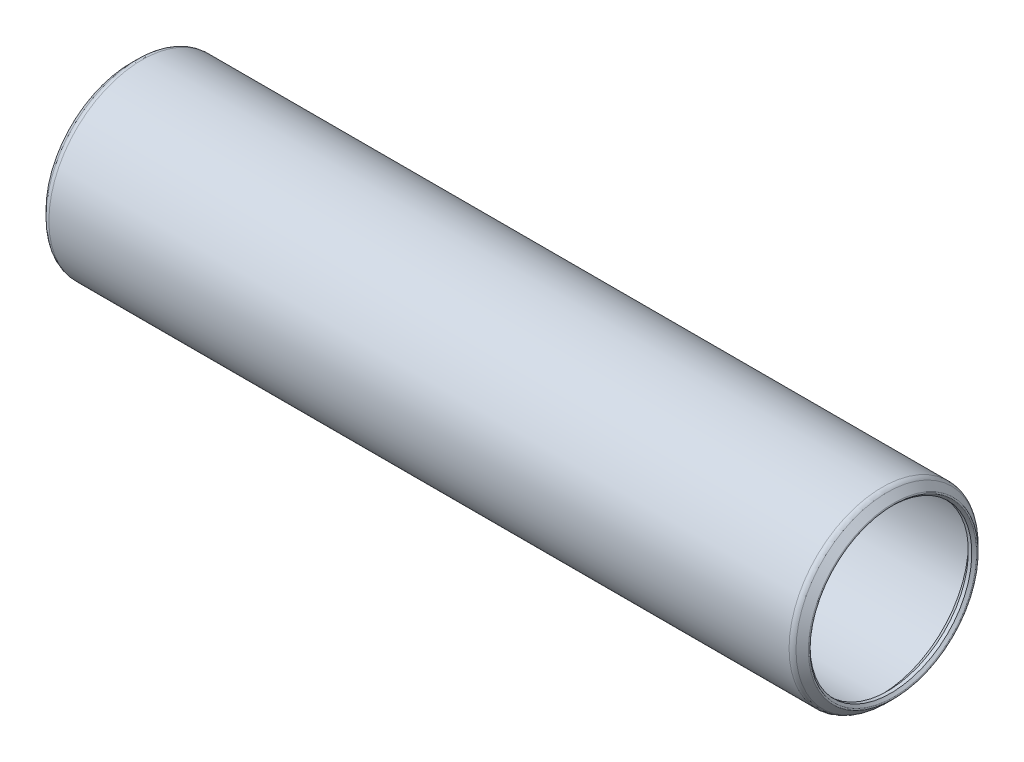
from build123d import *


with BuildPart() as part:
    # Sketch1 → Revolve1 (revolve)
    with BuildSketch(Plane.XY):
        with BuildLine():
            Line((-0.639512806, 9.167562806), (-0.381, 8.90905))
            Line((-0.381, 8.90905), (0, 8.90905))
            Line((0, 8.90905), (0.762, 9.67105))
            Line((0.762, 9.67105), (81.9277, 9.67105))
            Line((81.9277, 9.67105), (82.6897, 8.90905))
            Line((82.6897, 8.90905), (83.0707, 8.90905))
            Line((83.0707, 8.90905), (83.329212806, 9.167562806))
            ThreePointArc((83.329212806, 9.167562806), (83.366410245, 9.257365367), (83.329212806, 9.347167928))
            Line((83.329212806, 9.347167928), (82.644315367, 10.032065367))
            ThreePointArc((82.644315367, 10.032065367), (82.397104775, 10.197246204), (82.1055, 10.25525))
            Line((82.1055, 10.25525), (0.5842, 10.25525))
            ThreePointArc((0.5842, 10.25525), (0.292595225, 10.197246204), (0.045384633, 10.032065367))
            Line((0.045384633, 10.032065367), (-0.639512806, 9.347167928))
            ThreePointArc((-0.639512806, 9.347167928), (-0.676710245, 9.257365367), (-0.639512806, 9.167562806))
        make_face()
    revolve(axis=Axis((82.6897, 0, 0), (-1, 0, 0)))


solid = part.part
